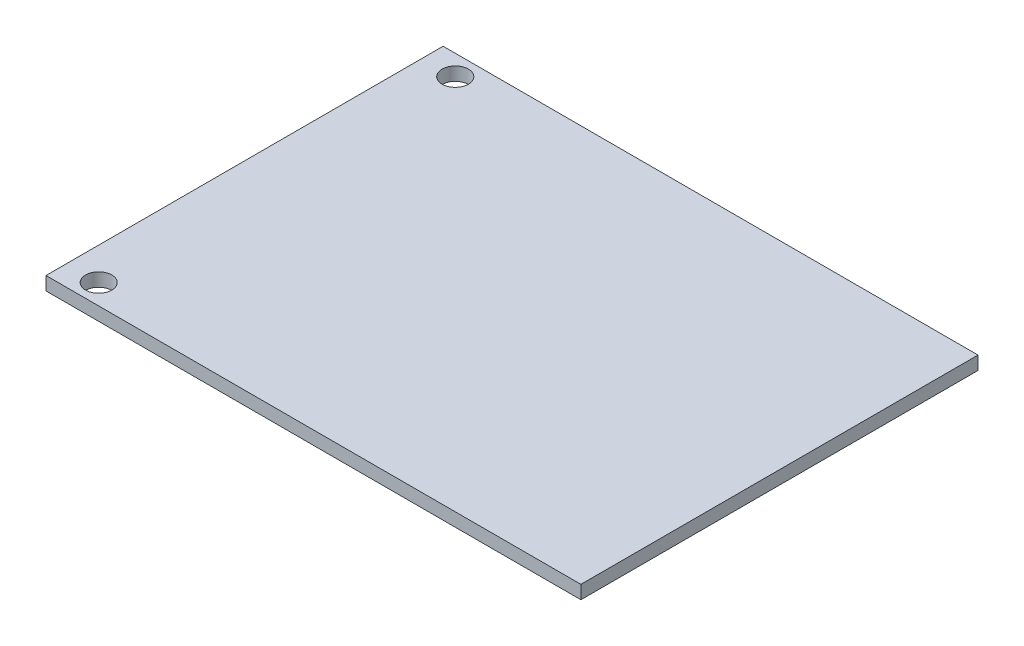
from build123d import *

# Parameters (mm, degrees)
SKETCH1_W           = 66
SKETCH1_H           = 49
BOSS_EXTRUDE1_DEPTH = 1.651
SKETCH2_R           = 1.62
CUT_EXTRUDE1_DEPTH  = 2.651


with BuildPart() as part:
    # Sketch1 → Boss-Extrude1 (new body)
    with BuildSketch(Plane(origin=(0, 0, 0), x_dir=(1, 0, 0), z_dir=(0, 1, 0))):
        Rectangle(SKETCH1_W, SKETCH1_H)
    extrude(amount=BOSS_EXTRUDE1_DEPTH)

    # Sketch2 → Cut-Extrude1 (cut, through all)
    with BuildSketch(Plane(origin=(0, 1.651, 0), x_dir=(1, 0, 0), z_dir=(0, 1, 0))):
        with Locations((-29, 22)):
            Circle(SKETCH2_R)
        with Locations((-29, -22)):
            Circle(SKETCH2_R)
    extrude(amount=-CUT_EXTRUDE1_DEPTH, mode=Mode.SUBTRACT)


solid = part.part
